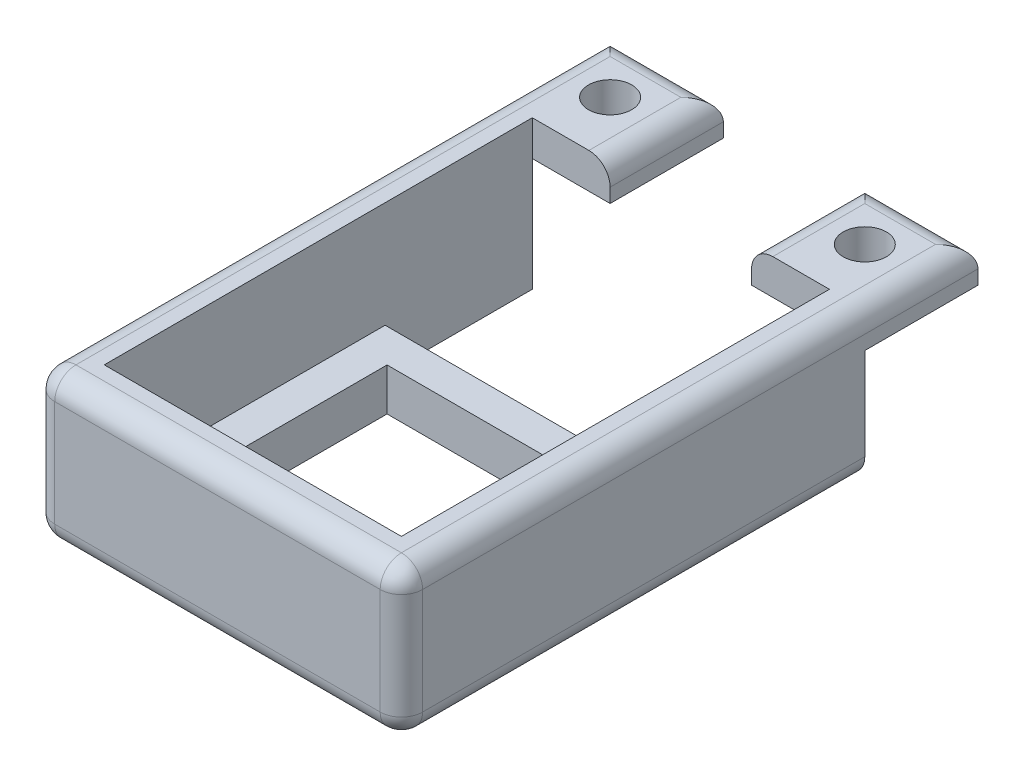
from build123d import *

# Parameters (mm, degrees)
SKETCH1_W           = 32
SKETCH1_H           = 30.247619048
BOSS_EXTRUDE1_DEPTH = 6
BOSS_EXTRUDE2_DEPTH = 21
BOSS_EXTRUDE3_START = 21
SKETCH1_6_R         = 3.05
BOSS_EXTRUDE3_DEPTH = 5
FILLET1_R           = 3


with BuildPart() as part:
    # Sketch1 → Boss-Extrude1 (new body)
    with BuildSketch(Plane(origin=(0, 0, 0), x_dir=(1, 0, 0), z_dir=(0, 1, 0))):
        Polygon((-26, 40.65), (-26, -24.85), (26, -24.85), (26, 40.65), (21, 40.65), (21, 19.85), (-21, 19.85), (-21, 40.65), align=None)
        Rectangle(SKETCH1_W, SKETCH1_H, mode=Mode.SUBTRACT)
    extrude(amount=BOSS_EXTRUDE1_DEPTH)

    # Sketch1_5 → Boss-Extrude2 (add)
    with BuildSketch(Plane(origin=(0, 0, 0), x_dir=(1, 0, 0), z_dir=(0, 1, 0))):
        Polygon((-26, 40.65), (-26, -24.85), (26, -24.85), (26, 40.65), (21, 40.65), (21, 19.85), (21, -19.85), (-21, -19.85), (-21, 19.85), (-21, 40.65), align=None)
    extrude(amount=BOSS_EXTRUDE2_DEPTH)

    # Sketch1_6 → Boss-Extrude3 (add)
    with BuildSketch(Plane(origin=(0, 0, 0), x_dir=(1, 0, 0), z_dir=(0, 1, 0)).offset(BOSS_EXTRUDE3_START)):
        Polygon((-26, 56.65), (-26, 40.65), (-21, 40.65), (-10, 40.65), (-10, 56.65), align=None)
        with Locations(Location((-18, 48.65, 0), (0, 0, 270))):  # turned: the seam where the file's is
            Circle(SKETCH1_6_R, mode=Mode.SUBTRACT)
        Polygon((21, 40.65), (26, 40.65), (26, 56.65), (10, 56.65), (10, 40.65), align=None)
        with Locations(Location((18, 48.65, 0), (0, 0, 270))):  # turned: the seam where the file's is
            Circle(SKETCH1_6_R, mode=Mode.SUBTRACT)
    extrude(amount=-BOSS_EXTRUDE3_DEPTH)

    # Fillet1
    fillet1_edges = [part.edges().sort_by_distance(p)[0] for p in [
        (26, 0, -7.9),
        (0, 0, 24.85),
        (-26, 0, -7.9),
        (26, 10.5, 24.85),
        (-26, 10.5, 24.85),
        (-26, 21, -15.9),
        (0, 21, 24.85),
        (26, 21, -15.9),
        (-10, 21, -48.65),
        (-18, 21, -56.65),
        (10, 21, -48.65),
        (18, 21, -56.65),
    ]]
    fillet(fillet1_edges, radius=FILLET1_R)


solid = part.part
